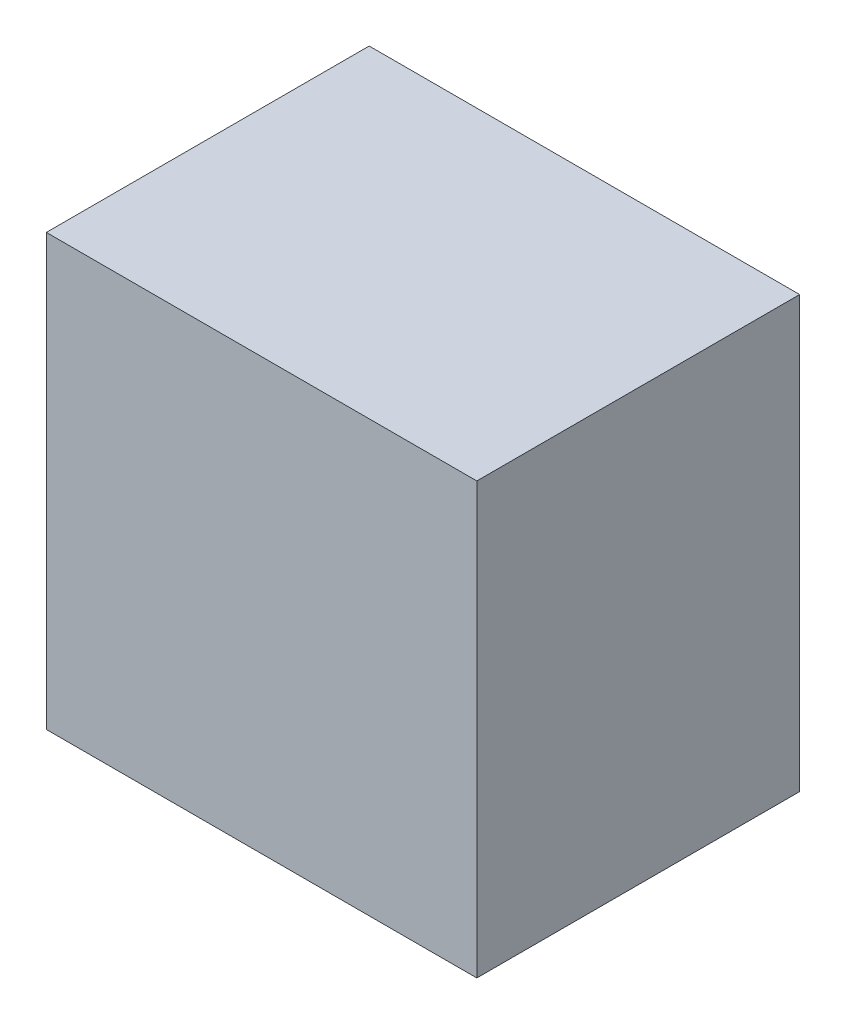
from build123d import *

# Parameters (mm, degrees)
SKETCH1_W           = 20
SKETCH1_H           = 20
BOSS_EXTRUDE1_DEPTH = 15


with BuildPart() as part:
    # Sketch1 → Boss-Extrude1 (new body)
    with BuildSketch(Plane.XY):
        Rectangle(SKETCH1_W, SKETCH1_H)
    extrude(amount=BOSS_EXTRUDE1_DEPTH)


solid = part.part
